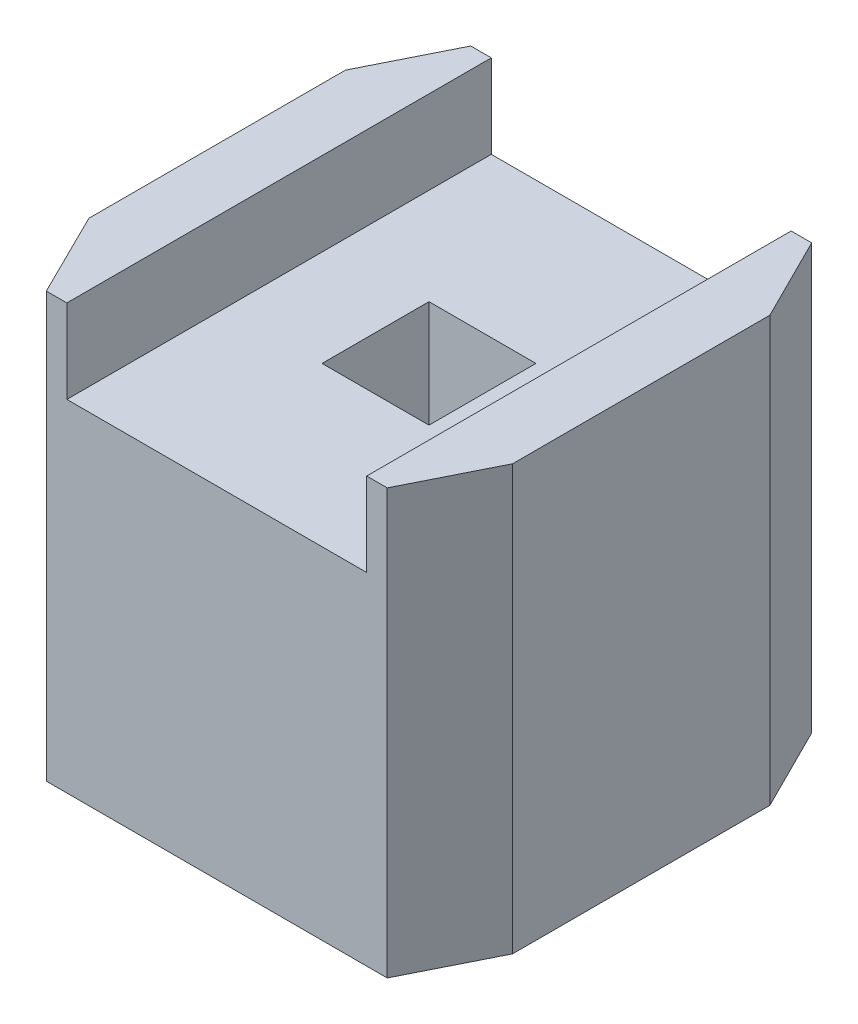
from build123d import *

# Parameters (mm, degrees)
SKETCH1_W           = 0.64
SKETCH1_H           = 0.64
BOSS_EXTRUDE1_DEPTH = 2.54
SKETCH3_W           = 1.79428953
SKETCH3_H           = 2.54
CUT_EXTRUDE1_DEPTH  = 0.5


with BuildPart() as part:
    # Sketch1 → Boss-Extrude1 (new body)
    with BuildSketch(Plane(origin=(0, 0, 0), x_dir=(1, 0, 0), z_dir=(0, 1, 0))):
        Polygon((-1.02, 1.27), (-1.27, 0.77), (-1.27, -0.765040333), (-1.02, -1.27), (1.02, -1.27), (1.27, -0.77), (1.27, 0.77), (1.02, 1.27), align=None)
        Rectangle(SKETCH1_W, SKETCH1_H, mode=Mode.SUBTRACT)
    extrude(amount=BOSS_EXTRUDE1_DEPTH)

    # Sketch3 → Cut-Extrude1 (cut)
    with BuildSketch(Plane(origin=(0, 2.54, 0), x_dir=(1, 0, 0), z_dir=(0, 1, 0))):
        Rectangle(SKETCH3_W, SKETCH3_H)
    extrude(amount=-CUT_EXTRUDE1_DEPTH, mode=Mode.SUBTRACT)


solid = part.part
